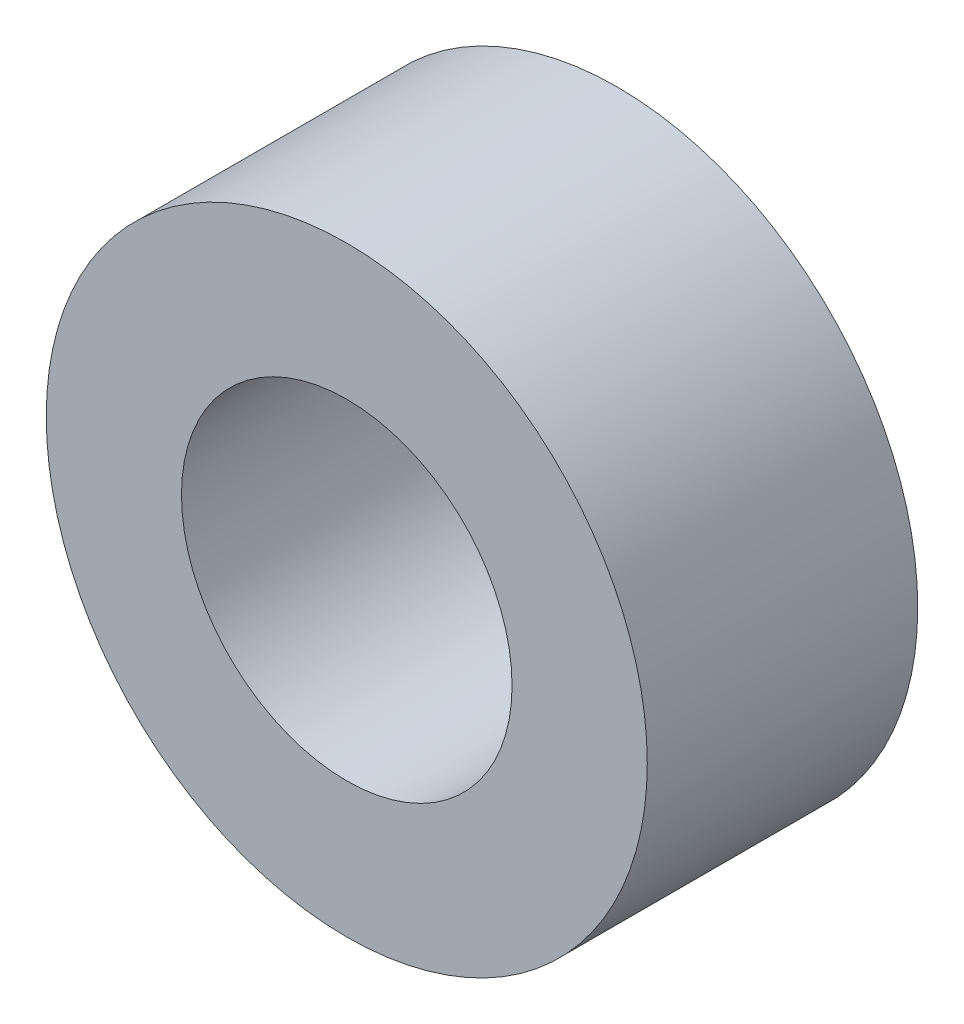
from build123d import *

# Parameters (mm, degrees)
SCHIZZO1_R                   = 5
ESTRUSIONE_ESTRUSIONE1_DEPTH = 4.5
TAGLIO_ESTRUSIONE1_REACH     = 6.5
SCHIZZO3_R                   = 2.75


with BuildPart() as part:
    # Schizzo1 → Estrusione-Estrusione1 (new body)
    with BuildSketch(Plane.XY):
        Circle(SCHIZZO1_R)
    extrude(amount=ESTRUSIONE_ESTRUSIONE1_DEPTH)

    # Schizzo3 → Taglio-Estrusione1 (cut, up to next)
    with BuildSketch(Plane.XY.offset(4.5), mode=Mode.PRIVATE) as taglio_estrusione1_sk1:
        Circle(SCHIZZO3_R)
    taglio_estrusione1_tool1 = extrude(taglio_estrusione1_sk1.sketch, amount=-TAGLIO_ESTRUSIONE1_REACH, mode=Mode.PRIVATE) & part.part
    add(taglio_estrusione1_tool1.solids().sort_by_distance((0, 0, 4.5))[0], mode=Mode.SUBTRACT)


solid = part.part
